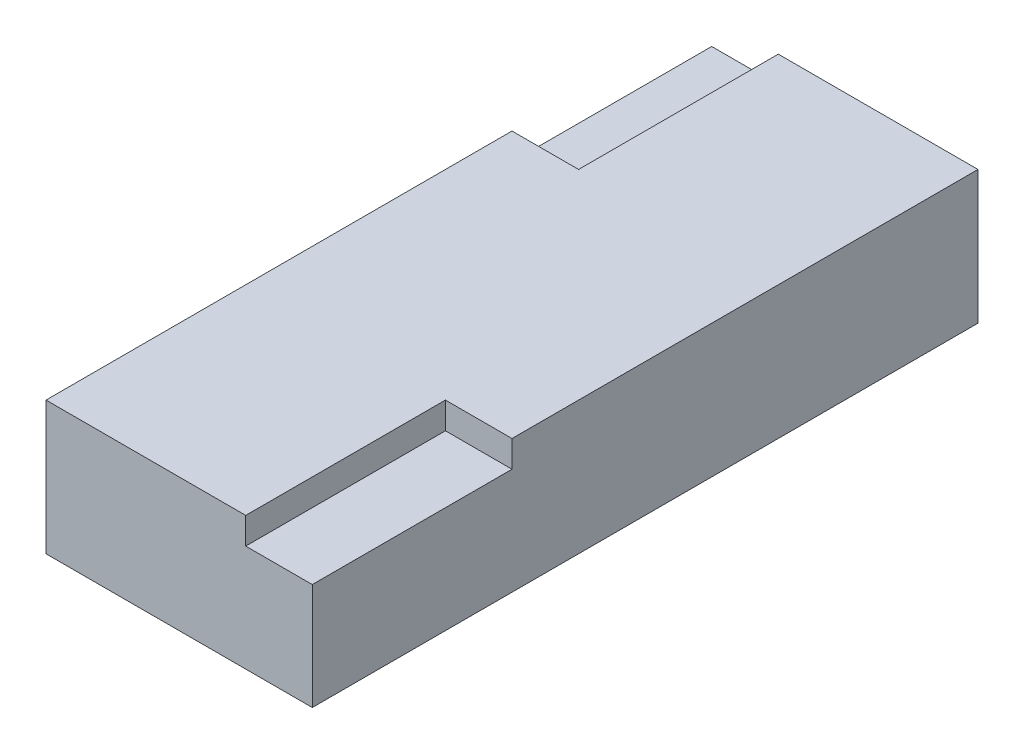
from build123d import *

# Parameters (mm, degrees)
SKETCH1_W           = 20
SKETCH1_H           = 50
BOSS_EXTRUDE1_DEPTH = 10
SKETCH2_W           = 5
SKETCH2_H           = 15
CUT_EXTRUDE1_DEPTH  = 2


with BuildPart() as part:
    # Sketch1 → Boss-Extrude1 (new body)
    with BuildSketch(Plane(origin=(0, 0, 0), x_dir=(1, 0, 0), z_dir=(0, 1, 0))):
        with Locations((10, 25)):
            Rectangle(SKETCH1_W, SKETCH1_H)
    extrude(amount=BOSS_EXTRUDE1_DEPTH)

    # Sketch2 → Cut-Extrude1 (cut)
    with BuildSketch(Plane(origin=(0, 10, 0), x_dir=(1, 0, 0), z_dir=(0, 1, 0))):
        with Locations((17.5, 7.5)):
            Rectangle(SKETCH2_W, SKETCH2_H)
        with Locations((2.5, 42.5)):
            Rectangle(SKETCH2_W, SKETCH2_H)
    extrude(amount=-CUT_EXTRUDE1_DEPTH, mode=Mode.SUBTRACT)


solid = part.part
